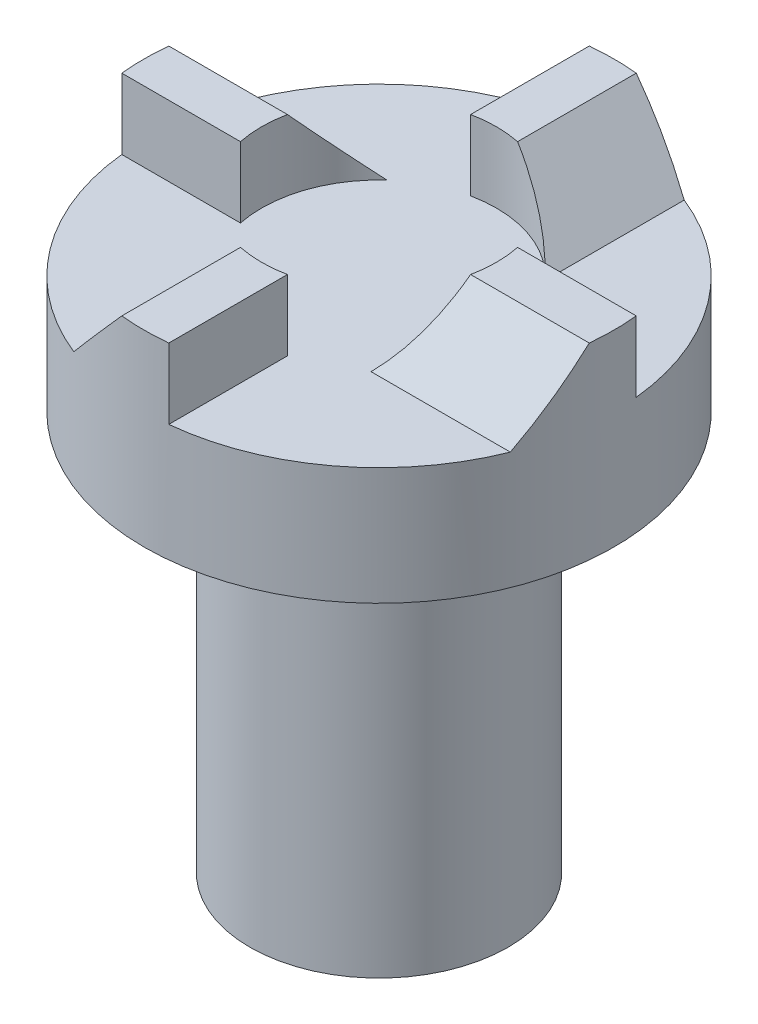
from build123d import *
from build123d.topology import SkipClean

# Parameters (mm, degrees)
SKETCH1_R               = 5.5
BOSS_EXTRUDE1_DEPTH     = 17
SKETCH2_R               = 10
BOSS_EXTRUDE2_DEPTH     = 5
BOSS_EXTRUDE3_DEPTH     = 3
BOSS_EXTRUDE4_START     = -6.6383
BOSS_EXTRUDE4_DEPTH     = 6.6383
CIRPATTERN1_COUNT       = 4
SKETCH10_R              = 13.301263659
CUT_EXTRUDE3_DEPTH      = 4
CUT_EXTRUDE3_DEPTH_BACK = 23
FILLET1_R               = 2
CUT_EXTRUDE4_DEPTH      = 6
SKETCH12_R              = 5
CUT_EXTRUDE5_DEPTH      = 3


with BuildPart() as part:
    # Sketch1 → Boss-Extrude1 (new body)
    with BuildSketch(Plane(origin=(0, 0, 0), x_dir=(1, 0, 0), z_dir=(0, 1, 0))):
        with Locations(Location((0, 0, 0), (0, 0, 270))):  # turned: the seam where the file's is
            Circle(SKETCH1_R)
    extrude(amount=BOSS_EXTRUDE1_DEPTH)

    # Sketch2 → Boss-Extrude2 (add)
    with BuildSketch(Plane(origin=(0, 17, 0), x_dir=(1, 0, 0), z_dir=(0, 1, 0))):
        with Locations(Location((0, 0, 0), (0, 0, 270))):  # turned: the seam where the file's is
            Circle(SKETCH2_R)
    extrude(amount=BOSS_EXTRUDE2_DEPTH)

    # Sketch4 → Boss-Extrude3 (add)
    with BuildSketch(Plane(origin=(0, 22, 0), x_dir=(1, 0, 0), z_dir=(0, 1, 0))):
        with BuildLine():
            Line((1, 10), (-1, 10))
            Line((-1, 10), (-1, 4.898979486))
            ThreePointArc((-1, 4.898979486), (-3.535533906, 3.535533906), (-4.898979486, 1))
            Line((-4.898979486, 1), (-10, 1))
            Line((-10, 1), (-10, -1))
            Line((-10, -1), (-4.898979486, -1))
            ThreePointArc((-4.898979486, -1), (-3.535533906, -3.535533906), (-1, -4.898979486))
            Line((-1, -4.898979486), (-1, -10))
            Line((-1, -10), (1, -10))
            Line((1, -10), (1, -4.898979486))
            ThreePointArc((1, -4.898979486), (3.535533906, -3.535533906), (4.898979486, -1))
            Line((4.898979486, -1), (10, -1))
            Line((10, -1), (10, 1))
            Line((10, 1), (4.898979486, 1))
            ThreePointArc((4.898979486, 1), (3.535533906, 3.535533906), (1, 4.898979486))
            Line((1, 4.898979486), (1, 10))
        make_face()
    extrude(amount=BOSS_EXTRUDE3_DEPTH)

    # Sketch9 → Boss-Extrude4 (add)
    with BuildSketch(Plane(origin=(0, 0, -10), x_dir=(-1, 0, 0), z_dir=(0, 0, -1)).offset(BOSS_EXTRUDE4_START)):
        Polygon((-1, 25), (-3.701212133, 22), (-1, 22), align=None)
    boss_extrude4 = extrude(amount=BOSS_EXTRUDE4_DEPTH)

    # CirPattern1: Boss-Extrude4 ×4 about axis
    cirpattern1_axis = Axis((0, 0, 0), (0, 1, 0))
    for i in range(1, CIRPATTERN1_COUNT):
        add(boss_extrude4.rotate(cirpattern1_axis, i * 360 / CIRPATTERN1_COUNT))

    # Sketch10 → Cut-Extrude3 (cut, two sides)
    with BuildSketch(Plane(origin=(0, 22, 0), x_dir=(1, 0, 0), z_dir=(0, 1, 0))) as cut_extrude3_sk:
        Circle(SKETCH10_R)
        with BuildLine():
            ThreePointArc((9.949874371, 1), (9.987460731, 0.500627751), (10, 0))
            ThreePointArc((10, 0), (-8.276838809, -5.611946127), (3.701212133, 9.2898347))
            ThreePointArc((3.701212133, 9.2898347), (7.985510661, 6.019270677), (9.949874371, 1))
        make_face(mode=Mode.SUBTRACT)
    extrude(amount=CUT_EXTRUDE3_DEPTH, mode=Mode.SUBTRACT)
    extrude(cut_extrude3_sk.sketch, amount=-CUT_EXTRUDE3_DEPTH_BACK, mode=Mode.SUBTRACT)

    # Fillet1
    fillet1_edges = [part.edges().sort_by_distance(p)[0] for p in [
        (0, 17, -5.5),
    ]]
    fillet(fillet1_edges, radius=FILLET1_R)

    # Sketch11 → Cut-Extrude4 (cut)
    with SkipClean():  # keep this step's faces unmerged: merging them makes the solid invalid here
        with BuildSketch(Plane.XZ):
            with BuildLine():
                Line((1.650181126, -2.0735), (1.650181126, 2.0735))
                ThreePointArc((1.650181126, 2.0735), (0, 2.65), (-1.650181126, 2.0735))
                Line((-1.650181126, 2.0735), (-1.650181126, -2.0735))
                ThreePointArc((-1.650181126, -2.0735), (0, -2.65), (1.650181126, -2.0735))
            make_face()
        extrude(amount=-CUT_EXTRUDE4_DEPTH, mode=Mode.SUBTRACT)

    # Sketch12 → Cut-Extrude5 (cut)
    with SkipClean():  # keep this step's faces unmerged: merging them makes the solid invalid here
        with BuildSketch(Plane(origin=(0, 25, 0), x_dir=(1, 0, 0), z_dir=(0, 1, 0))):
            Circle(SKETCH12_R)
        extrude(amount=-CUT_EXTRUDE5_DEPTH, mode=Mode.SUBTRACT)


solid = part.part
